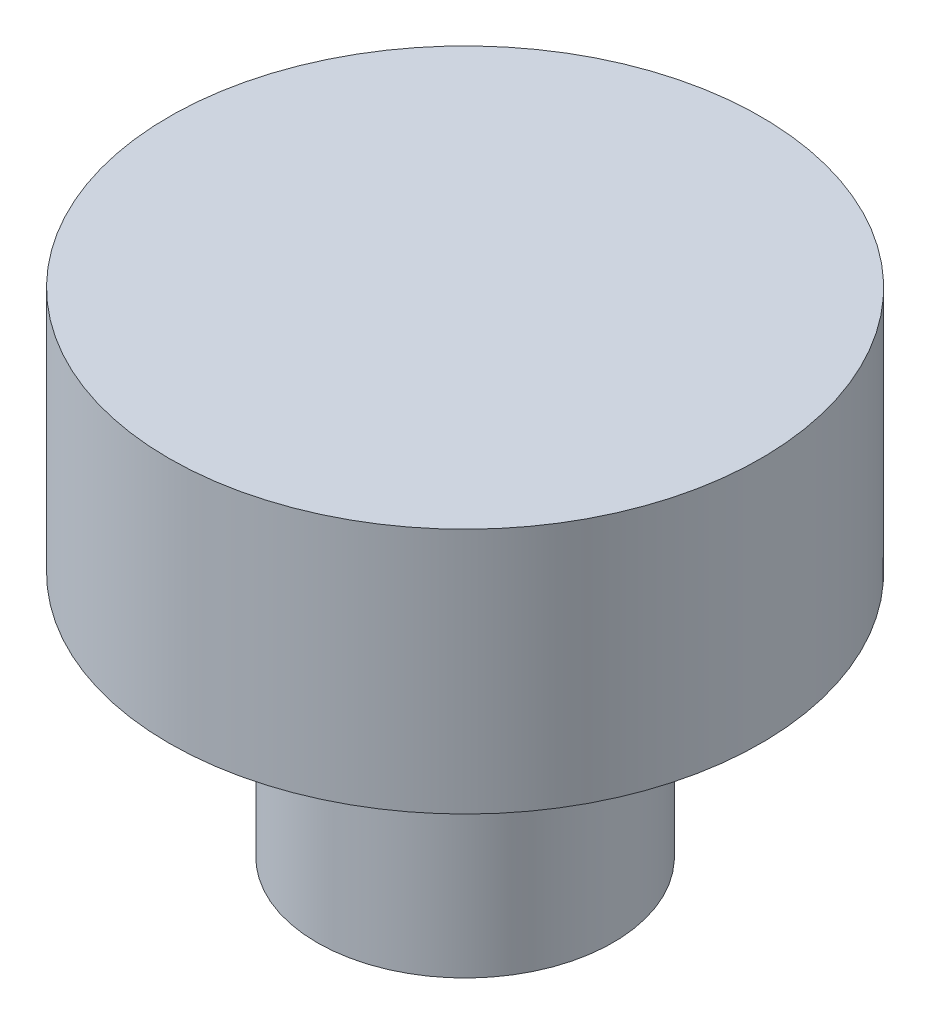
from build123d import *

# Parameters (mm, degrees)
SKETCH_1_R      = 6
EXTRUDE_1_DEPTH = 5
SKETCH_2_R      = 3
EXTRUDE_2_DEPTH = 5


with BuildPart() as part:
    # Эскиз1 → Бобышка-Вытянуть1 (new body)
    with BuildSketch(Plane(origin=(0, 0, 0), x_dir=(1, 0, 0), z_dir=(0, 1, 0))):
        Circle(SKETCH_1_R)
    extrude(amount=EXTRUDE_1_DEPTH)

    # Эскиз2 → Бобышка-Вытянуть2 (add)
    with BuildSketch(Plane(origin=(0, 0, 0), x_dir=(-1, 0, 0), z_dir=(0, -1, 0))):
        Circle(SKETCH_2_R)
    extrude(amount=EXTRUDE_2_DEPTH)


solid = part.part
